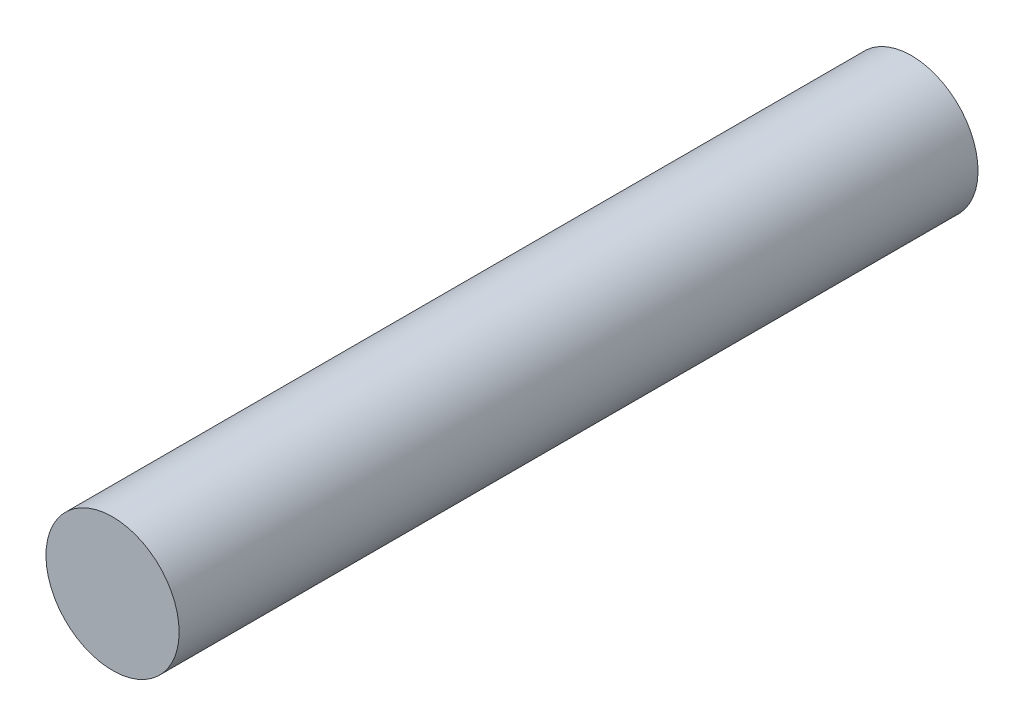
from build123d import *

# Parameters (mm, degrees)
SKETCH1_R           = 2.5
BOSS_EXTRUDE1_DEPTH = 15
CUT_EXTRUDE1_DEPTH  = 10


with BuildPart() as part:
    # Sketch1 → Boss-Extrude1 (new body, symmetric)
    with BuildSketch(Plane.XY):
        Circle(SKETCH1_R)
    extrude(amount=BOSS_EXTRUDE1_DEPTH, both=True)

    # Sketch2 → Cut-Extrude1 (cut)
    with BuildSketch(Plane(origin=(0, 0, -15), x_dir=(-1, 0, 0), z_dir=(0, 0, -1))):
        with BuildLine():
            Line((-0.5, -2.449489743), (-0.5, -1.949489743))
            Line((-0.5, -1.949489743), (0.5, -1.949489743))
            Line((0.5, -1.949489743), (0.5, -2.449489743))
            ThreePointArc((0.5, -2.449489743), (0, -2.5), (-0.5, -2.449489743))
        make_face()
    extrude(amount=-CUT_EXTRUDE1_DEPTH, mode=Mode.SUBTRACT)


solid = part.part
